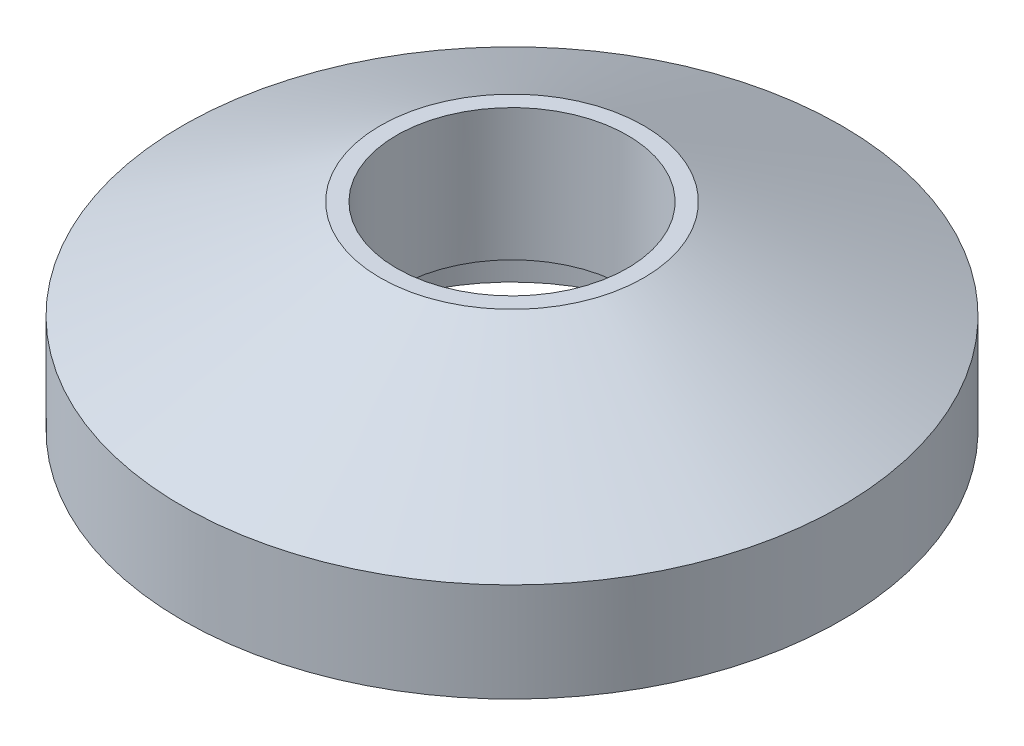
from build123d import *

# Parameters (mm, degrees)
CROQUIS1_R              = 50
SALIENTE_EXTRUIR1_DEPTH = 15
CROQUIS3_R              = 20
CROQUIS4_R              = 17.5
CORTAR_EXTRUIR1_DEPTH   = 77.811457609
CROQUIS5_R              = 27.5
CORTAR_EXTRUIR2_DEPTH   = 10


with BuildPart() as part:
    # Croquis1 → Saliente-Extruir1 (new body)
    with BuildSketch(Plane(origin=(0, 0, 0), x_dir=(1, 0, 0), z_dir=(0, 1, 0))):
        with Locations(Location((0, 0, 0), (0, 0, 270))):
            Circle(CROQUIS1_R)
    extrude(amount=SALIENTE_EXTRUIR1_DEPTH)

    # Croquis3 → section 0 of recubrir1
    with BuildSketch(Plane(origin=(0, 30, 0), x_dir=(1, 0, 0), z_dir=(0, 1, 0)), mode=Mode.PRIVATE) as recubrir1_s0:
        Circle(CROQUIS3_R)
    # loft up to a face of the part (recubrir1)
    loft([recubrir1_s0.sketch, Face(Wire([part.edges().sort_by_distance((36.448431371, 15, -34.227355296))[0]]))])

    # Croquis4 → Cortar-Extruir1 (cut, through all)
    with BuildSketch(Plane(origin=(0, 30, 0), x_dir=(1, 0, 0), z_dir=(0, 1, 0))):
        with Locations(Location((0, 0, 0), (0, 0, 270))):
            Circle(CROQUIS4_R)
    extrude(amount=-CORTAR_EXTRUIR1_DEPTH, mode=Mode.SUBTRACT)

    # Croquis5 → Cortar-Extruir2 (cut)
    with BuildSketch(Plane.XZ):
        with Locations(Location((0, 0, 0), (0, 0, 270))):
            Circle(CROQUIS5_R)
    extrude(amount=-CORTAR_EXTRUIR2_DEPTH, mode=Mode.SUBTRACT)


solid = part.part
